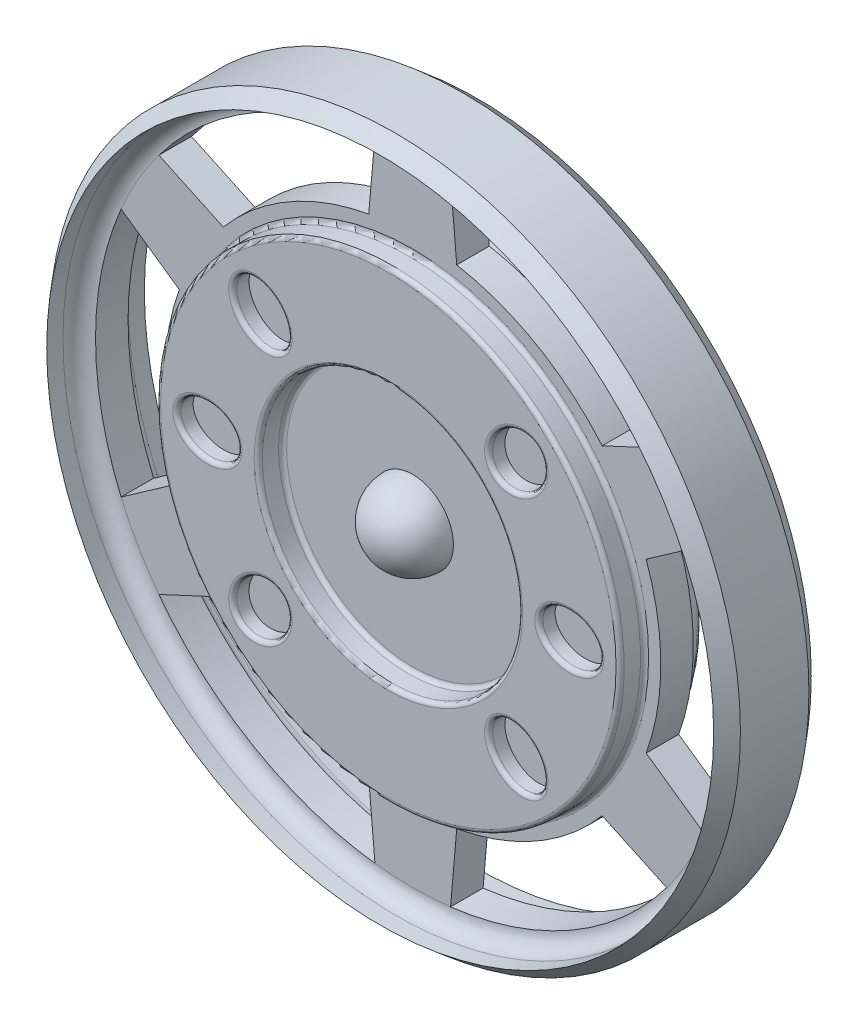
from build123d import *

# Parameters (mm, degrees)
OUTER_START                  = -23.86
OUTER_CUTS_DEPTH             = 37.56
OUTER_CUT_CIRPATTERN1_COUNT  = 6
SKETCH3_RX                   = 9.525
SKETCH3_RY                   = 7.62
CIRCLE_CUTS_DEPTH            = 5.08
CIRCLE_CUT_CIRPATTERN2_COUNT = 8
MIRROR1_COPY_1_SKETCH_RX     = 9.525
MIRROR1_COPY_1_SKETCH_RY     = 7.62
MIRROR1_COPY_1_DEPTH         = 5.08
MIRROR1_COPY_2_SKETCH_RX     = 9.525
MIRROR1_COPY_2_SKETCH_RY     = 7.62
MIRROR1_COPY_2_DEPTH         = 5.08
MIRROR1_COPY_3_SKETCH_RX     = 9.525
MIRROR1_COPY_3_SKETCH_RY     = 7.62
MIRROR1_COPY_3_DEPTH         = 5.08
MIRROR1_COPY_4_SKETCH_RX     = 9.525
MIRROR1_COPY_4_SKETCH_RY     = 7.62
MIRROR1_COPY_4_DEPTH         = 5.08
MIRROR1_COPY_5_SKETCH_RX     = 9.525
MIRROR1_COPY_5_SKETCH_RY     = 7.62
MIRROR1_COPY_5_DEPTH         = 5.08
FILLET3_R                    = 1.27


with BuildPart() as part:
    # Sketch1 → Base (revolve)
    with BuildSketch(Plane(origin=(0, 0, 0), x_dir=(0, 0, -1), z_dir=(1, 0, 0)), mode=Mode.PRIVATE) as base_sk:
        with BuildLine():
            Line((10.699418812, 107.95), (-10.699418812, 107.95))
            Line((-10.699418812, 107.95), (-15.24, 104.14))
            Line((-15.24, 104.14), (-10.16, 104.14))
            ThreePointArc((-10.16, 104.14), (-6.567897552, 102.652102448), (-5.08, 99.06))
            Line((-5.08, 99.06), (-5.08, 72.39))
            Line((-5.08, 72.39), (-12.7, 72.39))
            Line((-12.7, 72.39), (-12.7, 40.64))
            Line((-12.7, 40.64), (-5.08, 40.64))
            Line((-5.08, 40.64), (-5.08, 12.7))
            ThreePointArc((-5.08, 12.7), (-14.060256121, 8.980256121), (-17.78, 0))
            Line((-17.78, 0), (17.78, 0))
            ThreePointArc((17.78, 0), (14.060256121, 8.980256121), (5.08, 12.7))
            Line((5.08, 12.7), (5.08, 40.64))
            Line((5.08, 40.64), (12.7, 40.64))
            Line((12.7, 40.64), (12.7, 72.39))
            Line((12.7, 72.39), (5.08, 72.39))
            Line((5.08, 72.39), (5.08, 99.06))
            ThreePointArc((5.08, 99.06), (6.567897552, 102.652102448), (10.16, 104.14))
            Line((10.16, 104.14), (15.24, 104.14))
            Line((15.24, 104.14), (10.699418812, 107.95))
        make_face()
    revolve(base_sk.sketch.rotate(Axis((0, 0, 17.78), (0, 0, -1)), 90), axis=Axis((0, 0, 17.78), (0, 0, -1)))  # turned: the seam where the file's is

    # Sketch2 → Outer Cuts (cut)
    with BuildSketch(Plane.XY.offset(5.08).offset(OUTER_START)):
        with BuildLine():
            Line((-91.080557888, -38.951451511), (-72.898, -26.219887414))
            ThreePointArc((-72.898, -26.219887414), (-77.47, 0), (-72.898, 26.219887414))
            Line((-72.898, 26.219887414), (-91.080557888, 38.951451511))
            ThreePointArc((-91.080557888, 38.951451511), (-99.06, 0), (-91.080557888, -38.951451511))
        make_face()
    outer_cuts = extrude(amount=OUTER_CUTS_DEPTH, mode=Mode.SUBTRACT)

    # Outer Cut CirPattern1: Outer Cuts ×6 about axis
    outer_cut_cirpattern1_axis = Axis((0, 0, 0), (0, 0, 1))
    for i in range(1, OUTER_CUT_CIRPATTERN1_COUNT):
        add(outer_cuts.rotate(outer_cut_cirpattern1_axis, i * 360 / OUTER_CUT_CIRPATTERN1_COUNT), mode=Mode.SUBTRACT)

    # Sketch3 → Circle Cuts (cut)
    with BuildSketch(Plane.XY.offset(12.7)):
        with Locations(Location((-39.962139739, 39.962139739), (0, 0, -45))):
            Ellipse(SKETCH3_RX, SKETCH3_RY)
    circle_cuts = extrude(amount=-CIRCLE_CUTS_DEPTH, mode=Mode.SUBTRACT)

    # Circle Cut CirPattern2: Circle Cuts ×8 about axis, 2 skipped
    circle_cut_cirpattern2_axis = Axis((0, 0, 5.08), (0, 0, 1))
    add([circle_cuts.rotate(circle_cut_cirpattern2_axis, i * 360 / CIRCLE_CUT_CIRPATTERN2_COUNT) for i in range(1, CIRCLE_CUT_CIRPATTERN2_COUNT) if i not in (3, 7)], mode=Mode.SUBTRACT)

    # Mirror1: Circle Cuts across plane
    add(circle_cuts.mirror(Plane.XY), mode=Mode.SUBTRACT)

    # Mirror1 copy 1 sketch → Mirror1 copy 1 (cut)
    with BuildSketch(Plane(origin=(0, 0, -12.7), x_dir=(0.707106781, 0.707106781, 0), z_dir=(0, 0, -1))):
        with Locations(Location((-39.962139739, -39.962139739), (0, 0, 45))):
            Ellipse(MIRROR1_COPY_1_SKETCH_RX, MIRROR1_COPY_1_SKETCH_RY)
    extrude(amount=-MIRROR1_COPY_1_DEPTH, mode=Mode.SUBTRACT)

    # Mirror1 copy 2 sketch → Mirror1 copy 2 (cut)
    with BuildSketch(Plane.YX.offset(12.7)):
        with Locations(Location((-39.962139739, -39.962139739), (0, 0, 45))):
            Ellipse(MIRROR1_COPY_2_SKETCH_RX, MIRROR1_COPY_2_SKETCH_RY)
    extrude(amount=-MIRROR1_COPY_2_DEPTH, mode=Mode.SUBTRACT)

    # Mirror1 copy 3 sketch → Mirror1 copy 3 (cut)
    with BuildSketch(Plane(origin=(0, 0, -12.7), x_dir=(-1, 0, 0), z_dir=(0, 0, -1))):
        with Locations(Location((-39.962139739, -39.962139739), (0, 0, 45))):
            Ellipse(MIRROR1_COPY_3_SKETCH_RX, MIRROR1_COPY_3_SKETCH_RY)
    extrude(amount=-MIRROR1_COPY_3_DEPTH, mode=Mode.SUBTRACT)

    # Mirror1 copy 4 sketch → Mirror1 copy 4 (cut)
    with BuildSketch(Plane(origin=(0, 0, -12.7), x_dir=(-0.707106781, -0.707106781, 0), z_dir=(0, 0, -1))):
        with Locations(Location((-39.962139739, -39.962139739), (0, 0, 45))):
            Ellipse(MIRROR1_COPY_4_SKETCH_RX, MIRROR1_COPY_4_SKETCH_RY)
    extrude(amount=-MIRROR1_COPY_4_DEPTH, mode=Mode.SUBTRACT)

    # Mirror1 copy 5 sketch → Mirror1 copy 5 (cut)
    with BuildSketch(Plane(origin=(0, 0, -12.7), x_dir=(0, -1, 0), z_dir=(0, 0, -1))):
        with Locations(Location((-39.962139739, -39.962139739), (0, 0, 45))):
            Ellipse(MIRROR1_COPY_5_SKETCH_RX, MIRROR1_COPY_5_SKETCH_RY)
    extrude(amount=-MIRROR1_COPY_5_DEPTH, mode=Mode.SUBTRACT)

    # Fillet3
    fillet3_edges = [part.edges().sort_by_distance(p)[0] for p in [
        (-72.39, 0, -5.08),
        (-72.39, 0, -12.7),
        (-72.39, 0, 5.08),
        (46.698174811, 46.696488683, -12.7),
        (-46.698174811, 46.696488683, -12.7),
        (-40.64, 0, -12.7),
        (-66.039999883, 0.001192273, -12.7),
        (66.039999883, -0.001192273, -12.7),
        (46.696488683, -46.698174811, -12.7),
        (-46.698174811, -46.696488683, -12.7),
        (-72.39, 0, 12.7),
        (-40.64, 0, -5.08),
        (-46.698174811, 46.696488683, 12.7),
        (-66.039999883, -0.001192273, 12.7),
        (46.696488683, 46.698174811, 12.7),
        (-40.64, 0, 12.7),
        (-46.696488683, -46.698174811, 12.7),
        (66.039999883, 0.001192273, 12.7),
        (46.698174811, -46.696488683, 12.7),
        (-40.64, 0, 5.08),
    ]]
    fillet(fillet3_edges, radius=FILLET3_R)


solid = part.part
